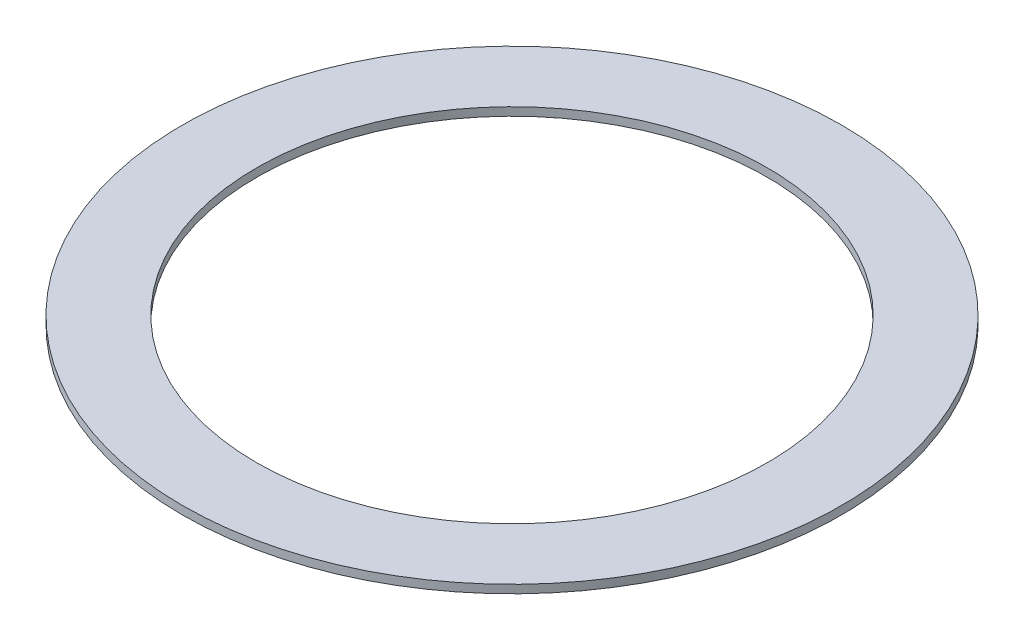
from build123d import *

# Parameters (mm, degrees)
ESQUISSE1_R        = 2
ESQUISSE1_R_2      = 1.55
BOSS_EXTRU_1_DEPTH = 0.05
ECHELLE1_SCALE     = 10


with BuildPart() as part:
    # Esquisse1 → Boss.-Extru.1 (new body)
    with BuildSketch(Plane(origin=(0, 0, 0), x_dir=(1, 0, 0), z_dir=(0, 1, 0))):
        Circle(ESQUISSE1_R)
        Circle(ESQUISSE1_R_2, mode=Mode.SUBTRACT)
    extrude(amount=BOSS_EXTRU_1_DEPTH)


with BuildPart() as part_1:
    # Echelle1: scaled about (0, 0, 0)
    add(part.part.scale(ECHELLE1_SCALE))


solid = part_1.part
